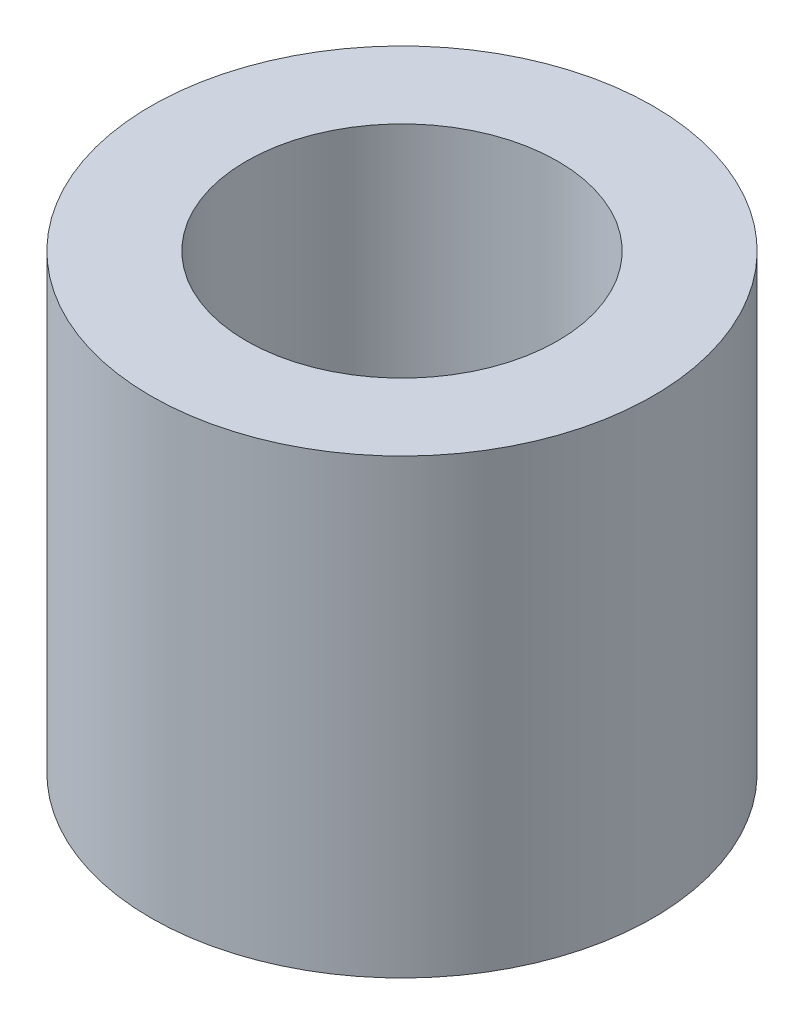
from build123d import *

# Parameters (mm, degrees)
SKETCH_1_R      = 2.5
SKETCH_1_R_2    = 1.55
EXTRUDE_1_DEPTH = 4.5


with BuildPart() as part:
    # 草图1 → 凸台-拉伸1 (new body)
    with BuildSketch(Plane(origin=(0, 0, 0), x_dir=(1, 0, 0), z_dir=(0, 1, 0))):
        Circle(SKETCH_1_R)
        Circle(SKETCH_1_R_2, mode=Mode.SUBTRACT)
    extrude(amount=EXTRUDE_1_DEPTH)


solid = part.part
